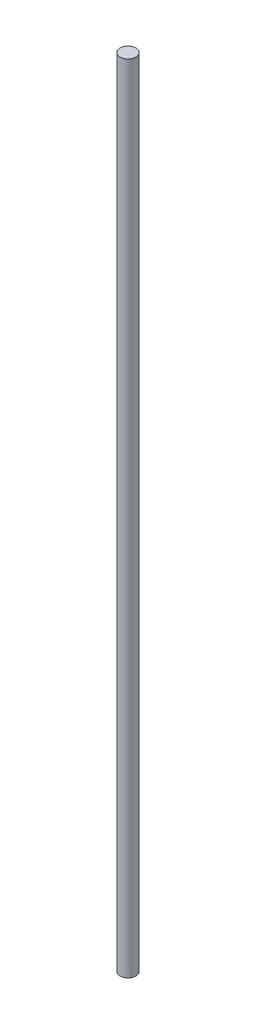
from build123d import *

# Parameters (mm, degrees)
SKICA1_R                = 4
P_IDAT_VYSUNUT_M1_DEPTH = 400


with BuildPart() as part:
    # Skica1 → Přidat vysunutím1 (new body)
    with BuildSketch(Plane(origin=(0, 0, 0), x_dir=(1, 0, 0), z_dir=(0, 1, 0))):
        Circle(SKICA1_R)
    extrude(amount=P_IDAT_VYSUNUT_M1_DEPTH)


solid = part.part
